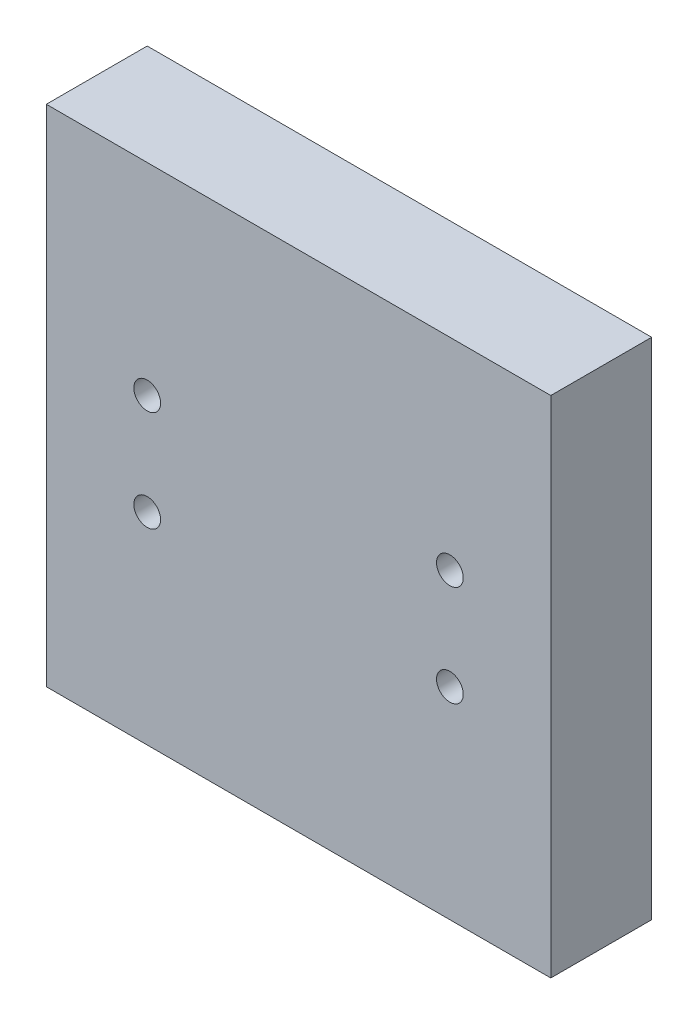
from build123d import *

# Parameters (mm, degrees)
SKETCH1_W                                       = 100
SKETCH1_H                                       = 100
BOSS_EXTRUDE1_DEPTH                             = 20
CSK_FOR_M5_FLAT_HEAD_MACHINE_SCREW1_D           = 5.3
CSK_FOR_M5_FLAT_HEAD_MACHINE_SCREW1_CSINK_D     = 10.4
CSK_FOR_M5_FLAT_HEAD_MACHINE_SCREW1_CSINK_ANGLE = 90


with BuildPart() as part:
    # Sketch1 → Boss-Extrude1 (new body)
    with BuildSketch(Plane.XY):
        Rectangle(SKETCH1_W, SKETCH1_H)
    extrude(amount=BOSS_EXTRUDE1_DEPTH)

    # CSK for M5 Flat Head Machine Screw1 (through all)
    with Locations(Plane(origin=(0, 0, 0), x_dir=(-1, 0, 0), z_dir=(0, 0, -1))):
        with Locations((-30, 10), (30, 10), (30, -10), (-30, -10)):
            CounterSinkHole(CSK_FOR_M5_FLAT_HEAD_MACHINE_SCREW1_D / 2, CSK_FOR_M5_FLAT_HEAD_MACHINE_SCREW1_CSINK_D / 2, counter_sink_angle=CSK_FOR_M5_FLAT_HEAD_MACHINE_SCREW1_CSINK_ANGLE)


solid = part.part
